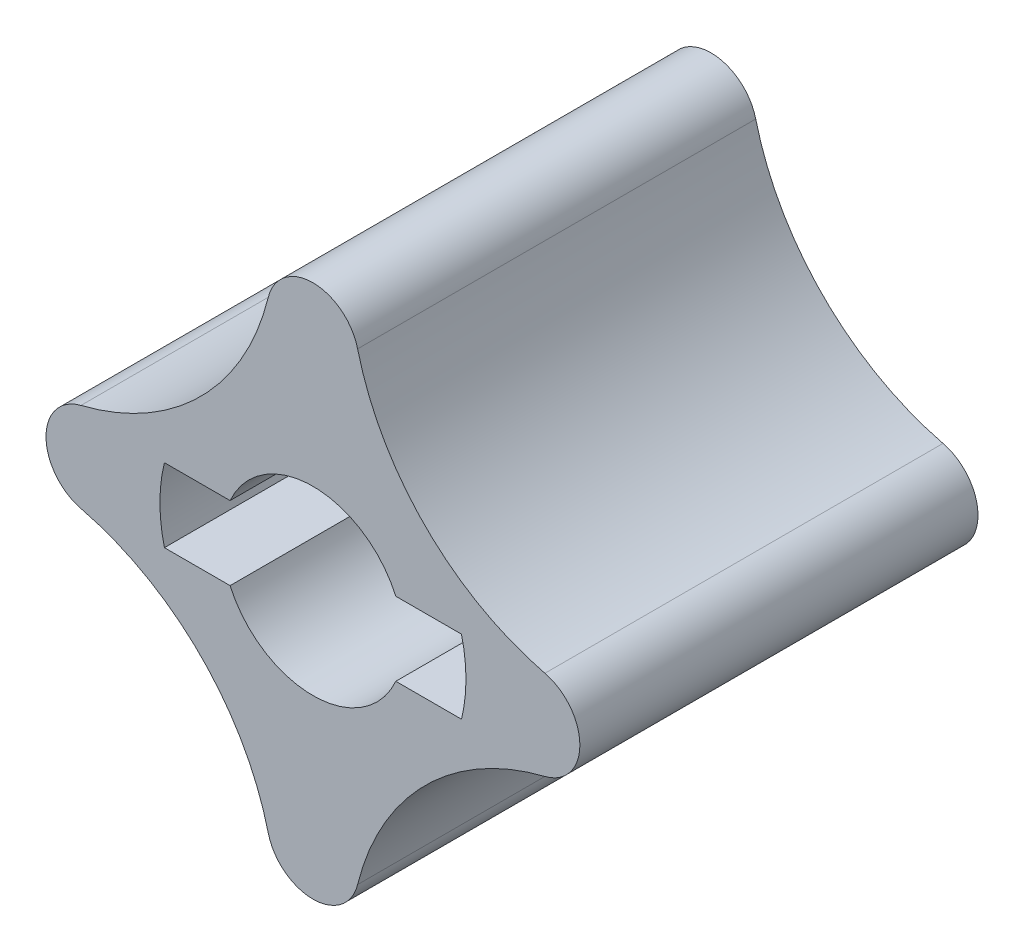
from build123d import *

# Parameters (mm, degrees)
SKETCH1_R          = 5.0038
BASE_EXTRUDE_DEPTH = 21.971
CUT_EXTRUDE1_DEPTH = 15.113


with BuildPart() as part:
    # Sketch1 → Base-Extrude (new body)
    with BuildSketch(Plane.XY):
        with BuildLine():
            ThreePointArc((2.465672848, 12.801965086), (0, 14.732), (-2.465672848, 12.801965086))
            ThreePointArc((-2.465672848, 12.801965086), (-6.195465294, 6.195465294), (-12.801965086, 2.465672848))
            ThreePointArc((-12.801965086, 2.465672848), (-14.732, 0), (-12.801965086, -2.465672848))
            ThreePointArc((-12.801965086, -2.465672848), (-6.195465294, -6.195465294), (-2.465672848, -12.801965086))
            ThreePointArc((-2.465672848, -12.801965086), (0, -14.732), (2.465672848, -12.801965086))
            ThreePointArc((2.465672848, -12.801965086), (6.195465294, -6.195465294), (12.801965086, -2.465672848))
            ThreePointArc((12.801965086, -2.465672848), (14.732, 0), (12.801965086, 2.465672848))
            ThreePointArc((12.801965086, 2.465672848), (6.195465294, 6.195465294), (2.465672848, 12.801965086))
        make_face()
        Circle(SKETCH1_R, mode=Mode.SUBTRACT)
    extrude(amount=BASE_EXTRUDE_DEPTH)

    # Sketch2 → Cut-Extrude1 (cut)
    with BuildSketch(Plane.XY.offset(21.971)):
        with BuildLine():
            Line((-8.197404848, 2.032), (8.197404848, 2.032))
            ThreePointArc((8.197404848, 2.032), (8.4455, 0), (8.197404848, -2.032))
            Line((8.197404848, -2.032), (-8.197404848, -2.032))
            ThreePointArc((-8.197404848, -2.032), (-8.4455, 0), (-8.197404848, 2.032))
        make_face()
    extrude(amount=-CUT_EXTRUDE1_DEPTH, mode=Mode.SUBTRACT)


solid = part.part
